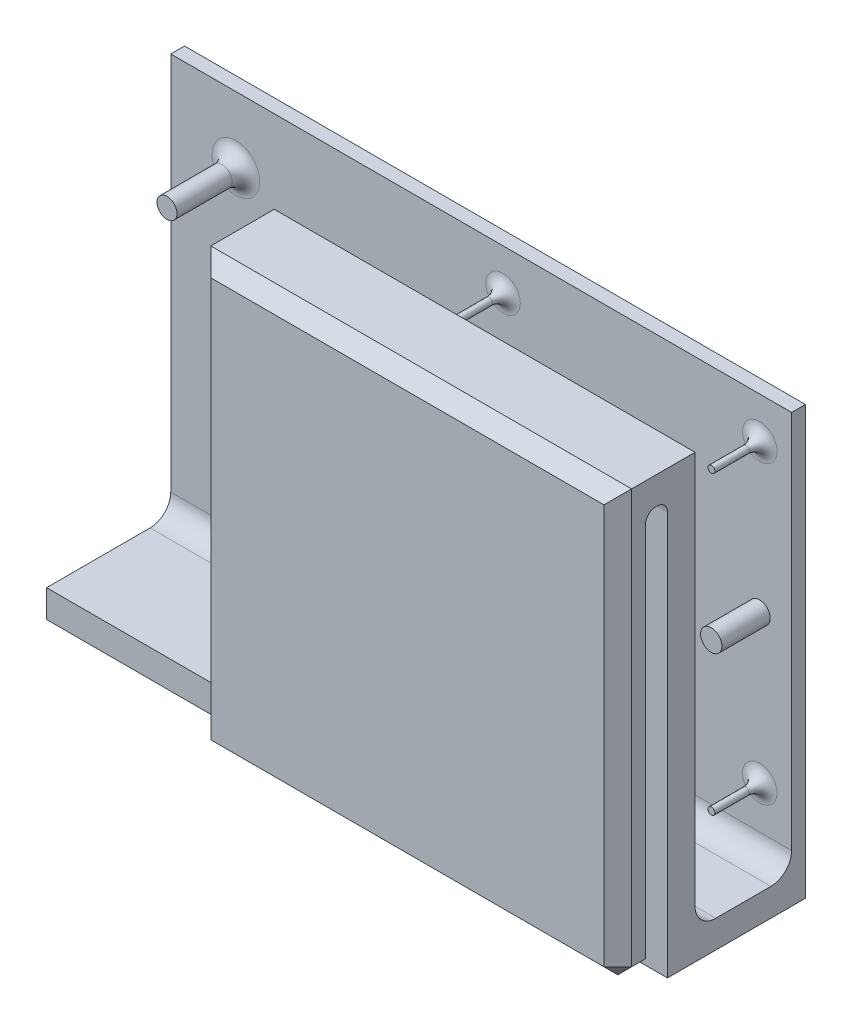
from build123d import *

# Parameters (mm, degrees)
EXTRUDE_THIN1_DEPTH = 90
SKETCH2_W           = 29
SKETCH2_H           = 11.2
CUT_EXTRUDE1_DEPTH  = 60
SKETCH3_W           = 29
SKETCH3_H           = 4
CUT_EXTRUDE2_DEPTH  = 5
SKETCH4_R           = 1.45
SKETCH4_R_2         = 1.4
BOSS_EXTRUDE1_DEPTH = 10
FILLET1_R           = 3
CHAMFER1_SIZE       = 2
SKETCH6_R           = 0.5
SKETCH6_R_2         = 1.55
BOSS_EXTRUDE2_DEPTH = 7
FILLET2_R           = 2
FILLET3_R           = 1.5


with BuildPart() as part:
    # Sketch1 → Extrude-Thin1 (new body)
    with BuildSketch(Plane(origin=(0, 0, 0), x_dir=(0, 0, -1), z_dir=(1, 0, 0))):
        Polygon((-5.2, -30), (-5.2, 28), (-2, 28), (-2, -32), (20, -32), (20, 30), (16, 30), (16, -28), (2, -28), (2, 32), (-9.2, 32), (-9.2, -30), align=None)
    extrude(amount=-EXTRUDE_THIN1_DEPTH)

    # Sketch2 → Cut-Extrude1 (cut)
    with BuildSketch(Plane(origin=(0, 32, 0), x_dir=(1, 0, 0), z_dir=(0, 1, 0))):
        with Locations((-75.5, -3.6)):
            Rectangle(SKETCH2_W, SKETCH2_H)
    extrude(amount=-CUT_EXTRUDE1_DEPTH, mode=Mode.SUBTRACT)

    # Sketch3 → Cut-Extrude2 (cut, through all)
    with BuildSketch(Plane(origin=(0, -28, 0), x_dir=(1, 0, 0), z_dir=(0, 1, 0))):
        with Locations((-75.5, -7.2)):
            Rectangle(SKETCH3_W, SKETCH3_H)
    extrude(amount=-CUT_EXTRUDE2_DEPTH, mode=Mode.SUBTRACT)

    # Sketch4 → Boss-Extrude1 (add)
    with BuildSketch(Plane.XY.offset(-16)):
        with Locations((-80.55, 20.4)):
            Circle(SKETCH4_R)
        with Locations((-52.4, -5.2)):
            Circle(SKETCH4_R_2)
    extrude(amount=BOSS_EXTRUDE1_DEPTH)

    # Fillet1
    fillet1_edges = [part.edges().sort_by_distance(p)[0] for p in [
        (-45, -28, -16),
        (-30.5, -28, -2),
    ]]
    fillet(fillet1_edges, radius=FILLET1_R)

    # Chamfer1
    chamfer1_edges = [part.edges().sort_by_distance(p)[0] for p in [
        (0, -1, -20),
        (0, -30, 7.2),
        (0, 1, 9.2),
        (-45, 30, -20),
        (-45, -32, -20),
        (-90, -1, -20),
        (-30.5, 32, 9.2),
        (-61, 1, 9.2),
        (-30.5, -30, 9.2),
        (-61, -30, 7.2),
    ]]
    chamfer(chamfer1_edges, length=CHAMFER1_SIZE)

    # Sketch6 → Boss-Extrude2 (add)
    with BuildSketch(Plane.XY.offset(-16)):
        with Locations((-41.83, 24.05)):
            Circle(SKETCH6_R)
        with Locations((-41.83, -18.85)):
            Circle(SKETCH6_R)
        with Locations((-41.8, 2.6)):
            Circle(SKETCH6_R_2)
        with Locations((-4.62, -18.85)):
            Circle(SKETCH6_R)
        with Locations((-4.65, 2.6)):
            Circle(SKETCH6_R_2)
        with Locations((-4.62, 24.05)):
            Circle(SKETCH6_R)
    extrude(amount=BOSS_EXTRUDE2_DEPTH)

    # Fillet2
    fillet2_edges = [part.edges().sort_by_distance(p)[0] for p in [
        (-42.33, -18.85, -16),
        (-42.33, 24.05, -16),
        (-5.12, -18.85, -16),
        (-5.12, 24.05, -16),
        (-82, 20.4, -16),
        (-53.8, -5.2, -16),
    ]]
    fillet(fillet2_edges, radius=FILLET2_R)

    # Fillet3
    fillet3_edges = [part.edges().sort_by_distance(p)[0] for p in [
        (-30.5, 28, 5.2),
        (-30.5, 28, 2),
    ]]
    fillet(fillet3_edges, radius=FILLET3_R)


solid = part.part
